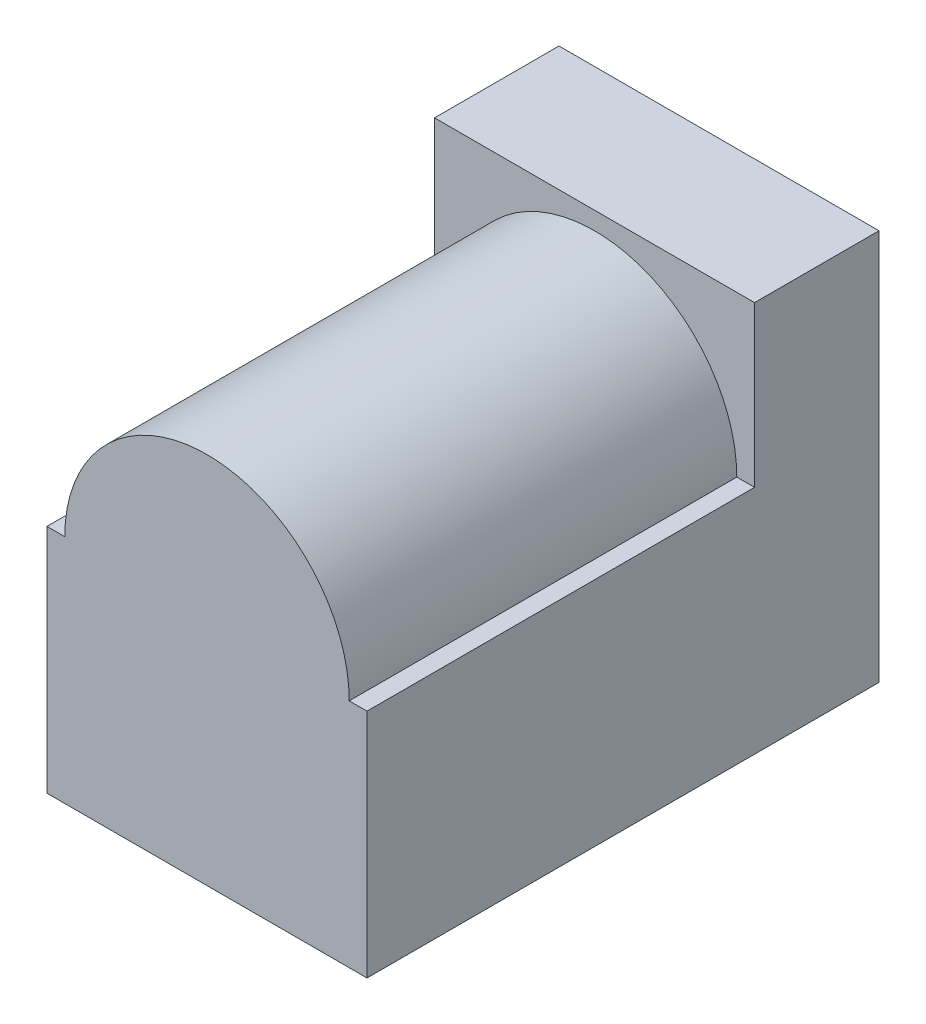
from build123d import *

# Parameters (mm, degrees)
SKETCH1_W           = 9
SKETCH1_H           = 11
BOSS_EXTRUDE1_DEPTH = 3.5
BOSS_EXTRUDE2_DEPTH = 14.4
SKETCH3_R           = 3.25
SKETCH3_R_2         = 1
CUT_EXTRUDE1_DEPTH  = 10


with BuildPart() as part:
    # Sketch1 → Boss-Extrude1 (new body)
    with BuildSketch(Plane.XY):
        with Locations((4.5, 5.5)):
            Rectangle(SKETCH1_W, SKETCH1_H)
    extrude(amount=BOSS_EXTRUDE1_DEPTH)

    # Sketch2 → Boss-Extrude2 (add)
    with BuildSketch(Plane(origin=(0, 0, 0), x_dir=(-1, 0, 0), z_dir=(0, 0, -1))):
        with BuildLine():
            Line((-0.5, 6.5), (0, 6.5))
            Line((0, 6.5), (0, 0))
            Line((0, 0), (-9, 0))
            Line((-9, 0), (-9, 6.5))
            Line((-9, 6.5), (-8.5, 6.5))
            ThreePointArc((-8.5, 6.5), (-4.5, 10.5), (-0.5, 6.5))
        make_face()
    extrude(amount=-BOSS_EXTRUDE2_DEPTH)

    # Sketch3 → Cut-Extrude1 (cut)
    with BuildSketch(Plane(origin=(0, 0, 0), x_dir=(-1, 0, 0), z_dir=(0, 0, -1))):
        with Locations((-4.5, 6.5)):
            Circle(SKETCH3_R)
        with Locations((-4.5, 6.5)):
            Circle(SKETCH3_R_2, mode=Mode.SUBTRACT)
    extrude(amount=-CUT_EXTRUDE1_DEPTH, mode=Mode.SUBTRACT)


solid = part.part
